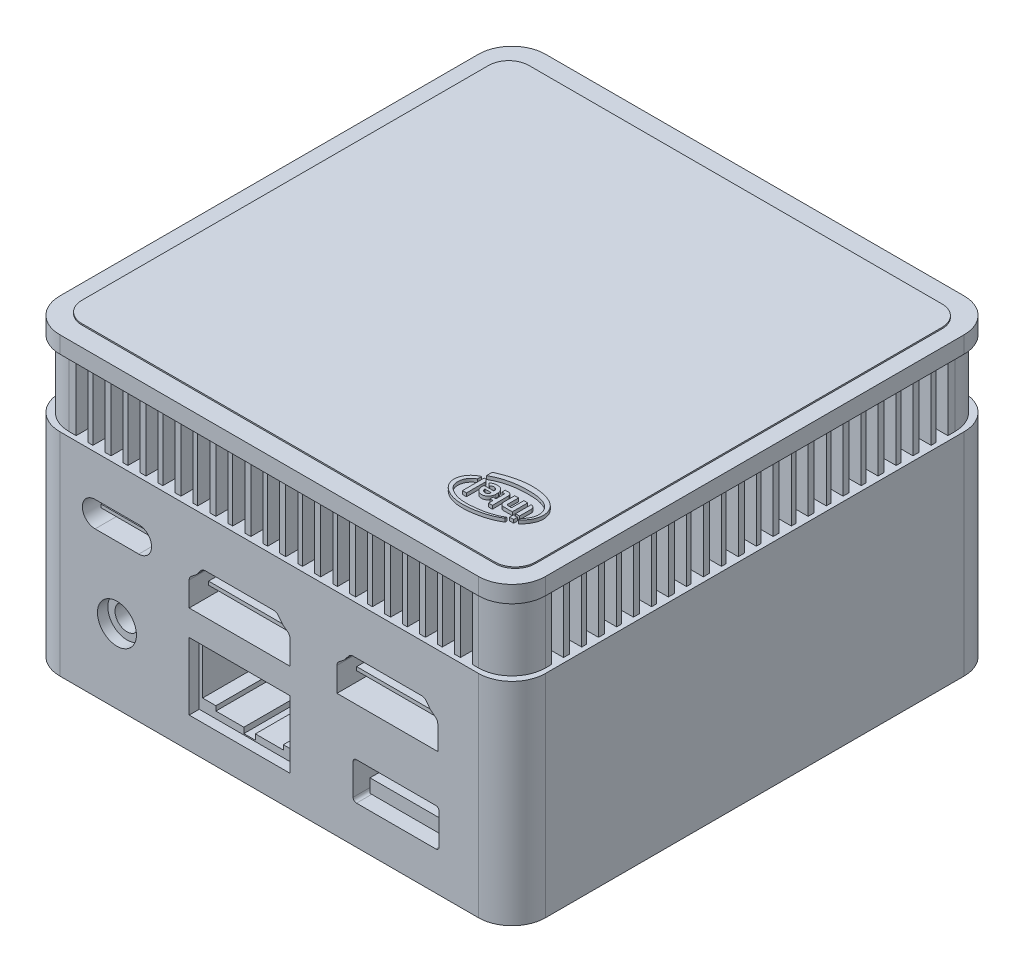
from build123d import *

# Parameters (mm, degrees)
EXTRUDE_1_DEPTH          = 31.5
EXTRUDE_2_DEPTH          = 10
SKETCH_3_W               = 1.8
SKETCH_3_H               = 4.65876044
SKETCH_3_W_2             = 4.65876044
SKETCH_3_H_2             = 1.8
CUT_EXTRUDE_1_DEPTH      = 10
EXTRUDE_3_DEPTH          = 2.5
EXTRUDE_4_DEPTH          = 0.2
SKETCH_6_R               = 5.2
SKETCH_6_R_2             = 0.75
CUT_EXTRUDE_2_DEPTH      = 0.5
CUT_EXTRUDE_3_DEPTH      = 0.5
CUT_EXTRUDE_4_DEPTH      = 10
CUT_EXTRUDE_4_DEPTH_BACK = 13.6
SKETCH_9_W               = 9.8
SKETCH_9_H               = 1.8
EXTRUDE_5_DEPTH          = 12.5
SKETCH_10_W              = 12.4
SKETCH_10_H              = 2
CUT_EXTRUDE_5_DEPTH      = 15
CUT_EXTRUDE_6_DEPTH      = 5
SKETCH_13_R              = 2.9
SKETCH_13_W              = 15
SKETCH_13_H              = 10
CUT_EXTRUDE_7_DEPTH      = 13.5
SKETCH_14_R              = 2.851807147
SKETCH_14_R_2            = 1.788206496
SKETCH_14_W              = 12.27057006
SKETCH_14_H              = 0.529318708
SKETCH_14_W_2            = 7.699181214
SKETCH_14_H_2            = 0.481198826
SKETCH_14_W_3            = 15
SKETCH_14_H_3            = 10
SKETCH_14_W_4            = 10.873667572
SKETCH_14_H_4            = 2.006450564
EXTRUDE_6_DEPTH          = 12
SKETCH_15_R              = 3.95
SKETCH_15_R_2            = 2.35
EXTRUDE_7_DEPTH          = 1.5
SKETCH_17_R              = 1
CUT_EXTRUDE_8_DEPTH      = 4
SKETCH_18_W              = 0.588452895
SKETCH_18_H              = 0.560154655
EXTRUDE_8_DEPTH          = 0.5


with BuildPart() as part:
    # 草图1 → 凸台-拉伸1 (new body)
    with BuildSketch(Plane(origin=(0, 0, 0), x_dir=(1, 0, 0), z_dir=(0, 1, 0))):
        with BuildLine():
            Line((-31.15, 36.15), (31.15, 36.15))
            ThreePointArc((31.15, 36.15), (34.685533906, 34.685533906), (36.15, 31.15))
            Line((36.15, 31.15), (36.15, -31.15))
            ThreePointArc((36.15, -31.15), (34.685533906, -34.685533906), (31.15, -36.15))
            Line((31.15, -36.15), (-31.15, -36.15))
            ThreePointArc((-31.15, -36.15), (-34.685533906, -34.685533906), (-36.15, -31.15))
            Line((-36.15, -31.15), (-36.15, 31.15))
            ThreePointArc((-36.15, 31.15), (-34.685533906, 34.685533906), (-31.15, 36.15))
        make_face()
    extrude(amount=EXTRUDE_1_DEPTH)

    # 草图2 → 凸台-拉伸2 (add)
    with BuildSketch(Plane(origin=(0, 31.5, 0), x_dir=(1, 0, 0), z_dir=(0, 1, 0))):
        with BuildLine():
            Line((-30.45, 35.45), (30.45, 35.45))
            ThreePointArc((30.45, 35.45), (33.985533906, 33.985533906), (35.45, 30.45))
            Line((35.45, 30.45), (35.45, -30.45))
            ThreePointArc((35.45, -30.45), (33.985533906, -33.985533906), (30.45, -35.45))
            Line((30.45, -35.45), (-30.45, -35.45))
            ThreePointArc((-30.45, -35.45), (-33.985533906, -33.985533906), (-35.45, -30.45))
            Line((-35.45, -30.45), (-35.45, 30.45))
            ThreePointArc((-35.45, 30.45), (-33.985533906, 33.985533906), (-30.45, 35.45))
        make_face()
    extrude(amount=EXTRUDE_2_DEPTH)

    # 草图3 → 切除-拉伸1 (cut)
    with BuildSketch(Plane(origin=(0, 41.5, 0), x_dir=(1, 0, 0), z_dir=(0, 1, 0))):
        with Locations((-28.675540816, 35.45)):
            Rectangle(SKETCH_3_W, SKETCH_3_H)
        with Locations((-25.975540816, 35.45)):
            Rectangle(SKETCH_3_W, SKETCH_3_H)
        with Locations((-20.775540816, 35.45)):
            Rectangle(SKETCH_3_W, SKETCH_3_H)
        with Locations((-23.475540816, 35.45)):
            Rectangle(SKETCH_3_W, SKETCH_3_H)
        with Locations((-15.575540816, 35.45)):
            Rectangle(SKETCH_3_W, SKETCH_3_H)
        with Locations((-18.275540816, 35.45)):
            Rectangle(SKETCH_3_W, SKETCH_3_H)
        with Locations((-10.375540816, 35.45)):
            Rectangle(SKETCH_3_W, SKETCH_3_H)
        with Locations((-13.075540816, 35.45)):
            Rectangle(SKETCH_3_W, SKETCH_3_H)
        with Locations((-5.175540816, 35.45)):
            Rectangle(SKETCH_3_W, SKETCH_3_H)
        with Locations((-7.875540816, 35.45)):
            Rectangle(SKETCH_3_W, SKETCH_3_H)
        with Locations((0.024459184, 35.45)):
            Rectangle(SKETCH_3_W, SKETCH_3_H)
        with Locations((-2.675540816, 35.45)):
            Rectangle(SKETCH_3_W, SKETCH_3_H)
        with Locations((5.224459184, 35.45)):
            Rectangle(SKETCH_3_W, SKETCH_3_H)
        with Locations((2.524459184, 35.45)):
            Rectangle(SKETCH_3_W, SKETCH_3_H)
        with Locations((10.424459184, 35.45)):
            Rectangle(SKETCH_3_W, SKETCH_3_H)
        with Locations((7.724459184, 35.45)):
            Rectangle(SKETCH_3_W, SKETCH_3_H)
        with Locations((15.624459184, 35.45)):
            Rectangle(SKETCH_3_W, SKETCH_3_H)
        with Locations((12.924459184, 35.45)):
            Rectangle(SKETCH_3_W, SKETCH_3_H)
        with Locations((20.824459184, 35.45)):
            Rectangle(SKETCH_3_W, SKETCH_3_H)
        with Locations((18.124459184, 35.45)):
            Rectangle(SKETCH_3_W, SKETCH_3_H)
        with Locations((26.024459184, 35.45)):
            Rectangle(SKETCH_3_W, SKETCH_3_H)
        with Locations((23.324459184, 35.45)):
            Rectangle(SKETCH_3_W, SKETCH_3_H)
        with Locations((28.524459184, 35.45)):
            Rectangle(SKETCH_3_W, SKETCH_3_H)
        with Locations((-35.45, -28.524459184)):
            Rectangle(SKETCH_3_W_2, SKETCH_3_H_2)
        with Locations((-35.45, -23.324459184)):
            Rectangle(SKETCH_3_W_2, SKETCH_3_H_2)
        with Locations((-35.45, -26.024459184)):
            Rectangle(SKETCH_3_W_2, SKETCH_3_H_2)
        with Locations((-35.45, -18.124459184)):
            Rectangle(SKETCH_3_W_2, SKETCH_3_H_2)
        with Locations((-35.45, -20.824459184)):
            Rectangle(SKETCH_3_W_2, SKETCH_3_H_2)
        with Locations((-35.45, -12.924459184)):
            Rectangle(SKETCH_3_W_2, SKETCH_3_H_2)
        with Locations((-35.45, -15.624459184)):
            Rectangle(SKETCH_3_W_2, SKETCH_3_H_2)
        with Locations((-35.45, -7.724459184)):
            Rectangle(SKETCH_3_W_2, SKETCH_3_H_2)
        with Locations((-35.45, -10.424459184)):
            Rectangle(SKETCH_3_W_2, SKETCH_3_H_2)
        with Locations((-35.45, -2.524459184)):
            Rectangle(SKETCH_3_W_2, SKETCH_3_H_2)
        with Locations((-35.45, -5.224459184)):
            Rectangle(SKETCH_3_W_2, SKETCH_3_H_2)
        with Locations((-35.45, 2.675540816)):
            Rectangle(SKETCH_3_W_2, SKETCH_3_H_2)
        with Locations((-35.45, -0.024459184)):
            Rectangle(SKETCH_3_W_2, SKETCH_3_H_2)
        with Locations((-35.45, 7.875540816)):
            Rectangle(SKETCH_3_W_2, SKETCH_3_H_2)
        with Locations((-35.45, 5.175540816)):
            Rectangle(SKETCH_3_W_2, SKETCH_3_H_2)
        with Locations((-35.45, 13.075540816)):
            Rectangle(SKETCH_3_W_2, SKETCH_3_H_2)
        with Locations((-35.45, 10.375540816)):
            Rectangle(SKETCH_3_W_2, SKETCH_3_H_2)
        with Locations((-35.45, 18.275540816)):
            Rectangle(SKETCH_3_W_2, SKETCH_3_H_2)
        with Locations((-35.45, 15.575540816)):
            Rectangle(SKETCH_3_W_2, SKETCH_3_H_2)
        with Locations((-35.45, 23.475540816)):
            Rectangle(SKETCH_3_W_2, SKETCH_3_H_2)
        with Locations((-35.45, 20.775540816)):
            Rectangle(SKETCH_3_W_2, SKETCH_3_H_2)
        with Locations((-35.45, 25.975540816)):
            Rectangle(SKETCH_3_W_2, SKETCH_3_H_2)
        with Locations((-35.45, 28.675540816)):
            Rectangle(SKETCH_3_W_2, SKETCH_3_H_2)
        with Locations((28.675540816, -35.45)):
            Rectangle(SKETCH_3_W, SKETCH_3_H)
        with Locations((25.975540816, -35.45)):
            Rectangle(SKETCH_3_W, SKETCH_3_H)
        with Locations((20.775540816, -35.45)):
            Rectangle(SKETCH_3_W, SKETCH_3_H)
        with Locations((23.475540816, -35.45)):
            Rectangle(SKETCH_3_W, SKETCH_3_H)
        with Locations((15.575540816, -35.45)):
            Rectangle(SKETCH_3_W, SKETCH_3_H)
        with Locations((18.275540816, -35.45)):
            Rectangle(SKETCH_3_W, SKETCH_3_H)
        with Locations((10.375540816, -35.45)):
            Rectangle(SKETCH_3_W, SKETCH_3_H)
        with Locations((13.075540816, -35.45)):
            Rectangle(SKETCH_3_W, SKETCH_3_H)
        with Locations((5.175540816, -35.45)):
            Rectangle(SKETCH_3_W, SKETCH_3_H)
        with Locations((7.875540816, -35.45)):
            Rectangle(SKETCH_3_W, SKETCH_3_H)
        with Locations((-0.024459184, -35.45)):
            Rectangle(SKETCH_3_W, SKETCH_3_H)
        with Locations((2.675540816, -35.45)):
            Rectangle(SKETCH_3_W, SKETCH_3_H)
        with Locations((-5.224459184, -35.45)):
            Rectangle(SKETCH_3_W, SKETCH_3_H)
        with Locations((-2.524459184, -35.45)):
            Rectangle(SKETCH_3_W, SKETCH_3_H)
        with Locations((-10.424459184, -35.45)):
            Rectangle(SKETCH_3_W, SKETCH_3_H)
        with Locations((-7.724459184, -35.45)):
            Rectangle(SKETCH_3_W, SKETCH_3_H)
        with Locations((-15.624459184, -35.45)):
            Rectangle(SKETCH_3_W, SKETCH_3_H)
        with Locations((-12.924459184, -35.45)):
            Rectangle(SKETCH_3_W, SKETCH_3_H)
        with Locations((-20.824459184, -35.45)):
            Rectangle(SKETCH_3_W, SKETCH_3_H)
        with Locations((-18.124459184, -35.45)):
            Rectangle(SKETCH_3_W, SKETCH_3_H)
        with Locations((-26.024459184, -35.45)):
            Rectangle(SKETCH_3_W, SKETCH_3_H)
        with Locations((-23.324459184, -35.45)):
            Rectangle(SKETCH_3_W, SKETCH_3_H)
        with Locations((-28.524459184, -35.45)):
            Rectangle(SKETCH_3_W, SKETCH_3_H)
        with Locations((35.45, 28.524459184)):
            Rectangle(SKETCH_3_W_2, SKETCH_3_H_2)
        with Locations((35.45, 23.324459184)):
            Rectangle(SKETCH_3_W_2, SKETCH_3_H_2)
        with Locations((35.45, 26.024459184)):
            Rectangle(SKETCH_3_W_2, SKETCH_3_H_2)
        with Locations((35.45, 18.124459184)):
            Rectangle(SKETCH_3_W_2, SKETCH_3_H_2)
        with Locations((35.45, 20.824459184)):
            Rectangle(SKETCH_3_W_2, SKETCH_3_H_2)
        with Locations((35.45, 12.924459184)):
            Rectangle(SKETCH_3_W_2, SKETCH_3_H_2)
        with Locations((35.45, 15.624459184)):
            Rectangle(SKETCH_3_W_2, SKETCH_3_H_2)
        with Locations((35.45, 7.724459184)):
            Rectangle(SKETCH_3_W_2, SKETCH_3_H_2)
        with Locations((35.45, 10.424459184)):
            Rectangle(SKETCH_3_W_2, SKETCH_3_H_2)
        with Locations((35.45, 2.524459184)):
            Rectangle(SKETCH_3_W_2, SKETCH_3_H_2)
        with Locations((35.45, 5.224459184)):
            Rectangle(SKETCH_3_W_2, SKETCH_3_H_2)
        with Locations((35.45, -2.675540816)):
            Rectangle(SKETCH_3_W_2, SKETCH_3_H_2)
        with Locations((35.45, 0.024459184)):
            Rectangle(SKETCH_3_W_2, SKETCH_3_H_2)
        with Locations((35.45, -7.875540816)):
            Rectangle(SKETCH_3_W_2, SKETCH_3_H_2)
        with Locations((35.45, -5.175540816)):
            Rectangle(SKETCH_3_W_2, SKETCH_3_H_2)
        with Locations((35.45, -13.075540816)):
            Rectangle(SKETCH_3_W_2, SKETCH_3_H_2)
        with Locations((35.45, -10.375540816)):
            Rectangle(SKETCH_3_W_2, SKETCH_3_H_2)
        with Locations((35.45, -18.275540816)):
            Rectangle(SKETCH_3_W_2, SKETCH_3_H_2)
        with Locations((35.45, -15.575540816)):
            Rectangle(SKETCH_3_W_2, SKETCH_3_H_2)
        with Locations((35.45, -23.475540816)):
            Rectangle(SKETCH_3_W_2, SKETCH_3_H_2)
        with Locations((35.45, -20.775540816)):
            Rectangle(SKETCH_3_W_2, SKETCH_3_H_2)
        with Locations((35.45, -25.975540816)):
            Rectangle(SKETCH_3_W_2, SKETCH_3_H_2)
        with Locations((35.45, -28.675540816)):
            Rectangle(SKETCH_3_W_2, SKETCH_3_H_2)
    extrude(amount=-CUT_EXTRUDE_1_DEPTH, mode=Mode.SUBTRACT)

    # 草图4 → 凸台-拉伸3 (add)
    with BuildSketch(Plane(origin=(0, 41.5, 0), x_dir=(1, 0, 0), z_dir=(0, 1, 0))):
        with BuildLine():
            Line((-31.15, -36.15), (31.15, -36.15))
            ThreePointArc((31.15, -36.15), (34.685533906, -34.685533906), (36.15, -31.15))
            Line((36.15, -31.15), (36.15, 31.15))
            ThreePointArc((36.15, 31.15), (34.685533906, 34.685533906), (31.15, 36.15))
            Line((31.15, 36.15), (-31.15, 36.15))
            ThreePointArc((-31.15, 36.15), (-34.685533906, 34.685533906), (-36.15, 31.15))
            Line((-36.15, 31.15), (-36.15, -31.15))
            ThreePointArc((-36.15, -31.15), (-34.685533906, -34.685533906), (-31.15, -36.15))
        make_face()
    extrude(amount=EXTRUDE_3_DEPTH)

    # 草图5 → 凸台-拉伸4 (add)
    with BuildSketch(Plane(origin=(0, 44, 0), x_dir=(1, 0, 0), z_dir=(0, 1, 0))):
        with BuildLine():
            Line((-30.75, 33.26831589), (30.75, 33.26831589))
            ThreePointArc((30.75, 33.26831589), (32.871320344, 32.389636233), (33.75, 30.26831589))
            Line((33.75, 30.26831589), (33.75, -30.26831589))
            ThreePointArc((33.75, -30.26831589), (32.871320344, -32.389636233), (30.75, -33.26831589))
            Line((30.75, -33.26831589), (-30.75, -33.26831589))
            ThreePointArc((-30.75, -33.26831589), (-32.871320344, -32.389636233), (-33.75, -30.26831589))
            Line((-33.75, -30.26831589), (-33.75, 30.26831589))
            ThreePointArc((-33.75, 30.26831589), (-32.871320344, 32.389636233), (-30.75, 33.26831589))
        make_face()
    extrude(amount=EXTRUDE_4_DEPTH)

    # 草图6 → 切除-拉伸2 (cut)
    with BuildSketch(Plane(origin=(0, 0, -36.15), x_dir=(-1, 0, 0), z_dir=(0, 0, -1))):
        with Locations((-20.65, 21)):
            Circle(SKETCH_6_R)
        with Locations((-20.65, 21)):
            Circle(SKETCH_6_R_2, mode=Mode.SUBTRACT)
    extrude(amount=-CUT_EXTRUDE_2_DEPTH, mode=Mode.SUBTRACT)

    # 草图7 → 切除-拉伸3 (cut)
    with BuildSketch(Plane(origin=(0, 0, -36.15), x_dir=(-1, 0, 0), z_dir=(0, 0, -1))):
        with BuildLine():
            Line((-7.35, 23), (26.15, 23))
            ThreePointArc((26.15, 23), (27.564213562, 22.414213562), (28.15, 21))
            Line((28.15, 21), (28.15, 15))
            ThreePointArc((28.15, 15), (27.564213562, 13.585786438), (26.15, 13))
            Line((26.15, 13), (-7.35, 13))
            ThreePointArc((-7.35, 13), (-8.764213562, 13.585786438), (-9.35, 15))
            Line((-9.35, 15), (-9.35, 21))
            ThreePointArc((-9.35, 21), (-8.764213562, 22.414213562), (-7.35, 23))
        make_face()
    extrude(amount=-CUT_EXTRUDE_3_DEPTH, mode=Mode.SUBTRACT)

    # 草图8 → 切除-拉伸4 (cut, two sides)
    with BuildSketch(Plane(origin=(0, 0, -35.65), x_dir=(-1, 0, 0), z_dir=(0, 0, -1))) as cut_extrude_4_sk:
        with BuildLine():
            Line((-6.55, 20.8), (4.65, 20.8))
            ThreePointArc((4.65, 20.8), (5.215685425, 20.565685425), (5.45, 20))
            Line((5.45, 20), (5.45, 16))
            ThreePointArc((5.45, 16), (5.215685425, 15.434314575), (4.65, 15.2))
            Line((4.65, 15.2), (-6.55, 15.2))
            ThreePointArc((-6.55, 15.2), (-7.115685425, 15.434314575), (-7.35, 16))
            Line((-7.35, 16), (-7.35, 20))
            ThreePointArc((-7.35, 20), (-7.115685425, 20.565685425), (-6.55, 20.8))
        make_face()
        with BuildLine():
            Line((14.25, 20.8), (25.45, 20.8))
            ThreePointArc((25.45, 20.8), (26.015685425, 20.565685425), (26.25, 20))
            Line((26.25, 20), (26.25, 16))
            ThreePointArc((26.25, 16), (26.015685425, 15.434314575), (25.45, 15.2))
            Line((25.45, 15.2), (14.25, 15.2))
            ThreePointArc((14.25, 15.2), (13.684314575, 15.434314575), (13.45, 16))
            Line((13.45, 16), (13.45, 20))
            ThreePointArc((13.45, 20), (13.684314575, 20.565685425), (14.25, 20.8))
        make_face()
    extrude(amount=CUT_EXTRUDE_4_DEPTH, mode=Mode.SUBTRACT)
    extrude(cut_extrude_4_sk.sketch, amount=-CUT_EXTRUDE_4_DEPTH_BACK, mode=Mode.SUBTRACT)

    # 草图9 → 凸台-拉伸5 (add)
    with BuildSketch(Plane(origin=(0, 0, -22.05), x_dir=(-1, 0, 0), z_dir=(0, 0, -1))):
        with Locations((-0.95, 18.9)):
            Rectangle(SKETCH_9_W, SKETCH_9_H)
        with Locations((19.85, 18.9)):
            Rectangle(SKETCH_9_W, SKETCH_9_H)
    extrude(amount=EXTRUDE_5_DEPTH)

    # 草图10 → 切除-拉伸5 (cut)
    with BuildSketch(Plane.ZY.offset(36.15)):
        with Locations((-8.95, 12)):
            Rectangle(SKETCH_10_W, SKETCH_10_H)
    extrude(amount=-CUT_EXTRUDE_5_DEPTH, mode=Mode.SUBTRACT)

    # 草图12 → 切除-拉伸6 (cut)
    with BuildSketch(Plane.ZY.offset(36.15)):
        with BuildLine():
            Line((11.35, 15.7), (17.65, 15.7))
            ThreePointArc((17.65, 15.7), (18.003553391, 15.553553391), (18.15, 15.2))
            Line((18.15, 15.2), (18.15, 11.7))
            ThreePointArc((18.15, 11.7), (18.003553391, 11.346446609), (17.65, 11.2))
            Line((17.65, 11.2), (11.35, 11.2))
            ThreePointArc((11.35, 11.2), (10.996446609, 11.346446609), (10.85, 11.7))
            Line((10.85, 11.7), (10.85, 15.2))
            ThreePointArc((10.85, 15.2), (10.996446609, 15.553553391), (11.35, 15.7))
        make_face()
    extrude(amount=-CUT_EXTRUDE_6_DEPTH, mode=Mode.SUBTRACT)

    # 草图13 → 切除-拉伸7 (cut)
    with BuildSketch(Plane.XY.offset(36.15)):
        with Locations((-22.65, 11)):
            Circle(SKETCH_13_R)
        with BuildLine():
            Line((-25.9, 25.4), (-19.4, 25.4))
            ThreePointArc((-19.4, 25.4), (-17.5, 23.5), (-19.4, 21.6))
            Line((-19.4, 21.6), (-25.9, 21.6))
            ThreePointArc((-25.9, 21.6), (-27.8, 23.5), (-25.9, 25.4))
        make_face()
        with BuildLine():
            Line((-11.9, 22.006931899), (-11.9, 18.4))
            Line((-11.9, 18.4), (3.1, 18.4))
            Line((3.1, 18.4), (3.1, 22.006931899))
            ThreePointArc((3.1, 22.006931899), (3.018013039, 22.359716926), (2.788856812, 22.640192523))
            Line((2.788856812, 22.640192523), (2.095640773, 23.175332984))
            ThreePointArc((2.095640773, 23.175332984), (2.018812159, 23.242908183), (1.95123696, 23.319736797))
            Line((1.95123696, 23.319736797), (1.357501074, 24.088856812))
            ThreePointArc((1.357501074, 24.088856812), (1.077025477, 24.318013039), (0.72424045, 24.4))
            Line((0.72424045, 24.4), (-9.52424045, 24.4))
            ThreePointArc((-9.52424045, 24.4), (-9.877025477, 24.318013039), (-10.157501074, 24.088856812))
            Line((-10.157501074, 24.088856812), (-10.75123696, 23.319736797))
            ThreePointArc((-10.75123696, 23.319736797), (-10.818812159, 23.242908183), (-10.895640773, 23.175332984))
            Line((-10.895640773, 23.175332984), (-11.588856812, 22.640192523))
            ThreePointArc((-11.588856812, 22.640192523), (-11.818013039, 22.359716926), (-11.9, 22.006931899))
        make_face()
        with Locations((-4.4, 9.6)):
            Rectangle(SKETCH_13_W, SKETCH_13_H)
        with BuildLine():
            Line((10.1, 22.006931899), (10.1, 18.4))
            Line((10.1, 18.4), (25.1, 18.4))
            Line((25.1, 18.4), (25.1, 22.006931899))
            ThreePointArc((25.1, 22.006931899), (25.018013039, 22.359716926), (24.788856812, 22.640192523))
            Line((24.788856812, 22.640192523), (24.095640773, 23.175332984))
            ThreePointArc((24.095640773, 23.175332984), (24.018812159, 23.242908183), (23.95123696, 23.319736797))
            Line((23.95123696, 23.319736797), (23.357501074, 24.088856812))
            ThreePointArc((23.357501074, 24.088856812), (23.077025477, 24.318013039), (22.72424045, 24.4))
            Line((22.72424045, 24.4), (12.47575955, 24.4))
            ThreePointArc((12.47575955, 24.4), (12.122974523, 24.318013039), (11.842498926, 24.088856812))
            Line((11.842498926, 24.088856812), (11.24876304, 23.319736797))
            ThreePointArc((11.24876304, 23.319736797), (11.181187841, 23.242908183), (11.104359227, 23.175332984))
            Line((11.104359227, 23.175332984), (10.411143188, 22.640192523))
            ThreePointArc((10.411143188, 22.640192523), (10.181986961, 22.359716926), (10.1, 22.006931899))
        make_face()
        with BuildLine():
            Line((13, 11.3), (24.8, 11.3))
            ThreePointArc((24.8, 11.3), (25.153553391, 11.153553391), (25.3, 10.8))
            Line((25.3, 10.8), (25.3, 6.2))
            ThreePointArc((25.3, 6.2), (25.153553391, 5.846446609), (24.8, 5.7))
            Line((24.8, 5.7), (13, 5.7))
            ThreePointArc((13, 5.7), (12.646446609, 5.846446609), (12.5, 6.2))
            Line((12.5, 6.2), (12.5, 10.8))
            ThreePointArc((12.5, 10.8), (12.646446609, 11.153553391), (13, 11.3))
        make_face()
    extrude(amount=-CUT_EXTRUDE_7_DEPTH, mode=Mode.SUBTRACT)

    # 草图14 → 凸台-拉伸6 (add)
    with BuildSketch(Plane.XY.offset(22.65)):
        with Locations((-22.65, 11)):
            Circle(SKETCH_14_R)
        with Locations((-22.65, 11)):
            Circle(SKETCH_14_R_2, mode=Mode.SUBTRACT)
        with Locations((17.672745661, 21.54662135)):
            Rectangle(SKETCH_14_W, SKETCH_14_H)
        with Locations((-22.68852464, 23.495476595)):
            Rectangle(SKETCH_14_W_2, SKETCH_14_H_2)
        with Locations((-4.378909316, 21.54662135)):
            Rectangle(SKETCH_14_W, SKETCH_14_H)
        with Locations((-4.4, 9.6)):
            Rectangle(SKETCH_14_W_3, SKETCH_14_H_3)
        Polygon((-11.4, 14.095061531), (-11.4, 6.294314474), (-9.42049085, 6.294314474), (-9.42049085, 5.605542147), (-5.258720162, 5.605542147), (-5.258720162, 4.778804827), (-3.541279838, 4.778804827), (-3.541279838, 5.605542147), (0.62049085, 5.605542147), (0.62049085, 6.294314474), (2.6, 6.294314474), (2.6, 14.095061531), align=None, mode=Mode.SUBTRACT)
        with Locations((18.952613797, 7.467625954)):
            Rectangle(SKETCH_14_W_4, SKETCH_14_H_4)
    extrude(amount=EXTRUDE_6_DEPTH)

    # 草图15 → 凸台-拉伸7 (add)
    with BuildSketch(Plane.XZ):
        with Locations((29.25, 29.25)):
            Circle(SKETCH_15_R)
        with Locations((29.25, 29.25)):
            Circle(SKETCH_15_R_2, mode=Mode.SUBTRACT)
        with Locations((-29.25, 29.25)):
            Circle(SKETCH_15_R)
        with Locations((-29.25, 29.25)):
            Circle(SKETCH_15_R_2, mode=Mode.SUBTRACT)
        with Locations((-29.25, -29.25)):
            Circle(SKETCH_15_R)
        with Locations((-29.25, -29.25)):
            Circle(SKETCH_15_R_2, mode=Mode.SUBTRACT)
        with Locations((29.25, -29.25)):
            Circle(SKETCH_15_R)
        with Locations((29.25, -29.25)):
            Circle(SKETCH_15_R_2, mode=Mode.SUBTRACT)
    extrude(amount=EXTRUDE_7_DEPTH)

    # 草图17 → 切除-拉伸8 (cut)
    with BuildSketch(Plane.XZ):
        with Locations((27.25, 0)):
            Circle(SKETCH_17_R)
        with Locations((-27.25, 0)):
            Circle(SKETCH_17_R)
    extrude(amount=-CUT_EXTRUDE_8_DEPTH, mode=Mode.SUBTRACT)

    # 草图18 → 凸台-拉伸8 (add)
    with BuildSketch(Plane(origin=(0, 44.2, 0), x_dir=(1, 0, 0), z_dir=(0, 1, 0))):
        with BuildLine():
            Line((27.129073137, -26.007984189), (27.129073137, -24.22823144))
            add(Edge.make_bspline(
                [(27.129073137, -24.22823144), (27.066600773, -23.814474055), (26.797568667, -23.691408765), (26.53341077, -23.704149535)],
                knots=[0, 0, 0, 0, 1, 1, 1, 1], degree=3))
            Line((26.53341077, -23.704149535), (26.53341077, -26.007984189))
            Line((26.53341077, -26.007984189), (27.129073137, -26.007984189))
        make_face()
        with Locations((26.83484669, -26.610952158)):
            Rectangle(SKETCH_18_W, SKETCH_18_H)
        with BuildLine():
            Line((26.043235848, -26.004453525), (26.043235848, -23.700618871))
            Line((26.043235848, -23.700618871), (25.465757492, -23.700618871))
            Line((25.465757492, -23.700618871), (25.465757492, -25.537976363))
            Line((25.465757492, -25.537976363), (24.903563318, -25.537976363))
            ThreePointArc((24.903563318, -25.537976363), (24.778784674, -25.486291357), (24.727099667, -25.361512713))
            Line((24.727099667, -25.361512713), (24.727099667, -23.742373005))
            Line((24.727099667, -23.742373005), (24.151434589, -23.742373005))
            Line((24.151434589, -23.742373005), (24.151434589, -25.360112493))
            ThreePointArc((24.151434589, -25.360112493), (24.285927469, -25.793267506), (24.687315144, -26.004453525))
            Line((24.687315144, -26.004453525), (26.043235848, -26.004453525))
        make_face()
        with BuildLine():
            Line((23.742604959, -26.654378496), (23.709253493, -24.235479724))
            ThreePointArc((23.709253493, -24.235479724), (23.560408802, -23.886390814), (23.209301013, -23.742373005))
            Line((23.209301013, -23.742373005), (22.729565957, -23.742373005))
            Line((22.729565957, -23.742373005), (22.729565957, -24.22823144))
            Line((22.729565957, -24.22823144), (23.057618269, -24.22823144))
            ThreePointArc((23.057618269, -24.22823144), (23.128328947, -24.257520762), (23.157618269, -24.32823144))
            Line((23.157618269, -24.32823144), (23.157618269, -25.537976363))
            Line((23.157618269, -25.537976363), (22.729565957, -25.537976363))
            Line((22.729565957, -25.537976363), (22.729565957, -26.004453525))
            Line((22.729565957, -26.004453525), (23.157618269, -26.004453525))
            Line((23.157618269, -26.004453525), (23.157618269, -26.654378496))
            Line((23.157618269, -26.654378496), (23.742604959, -26.654378496))
        make_face()
        with BuildLine():
            Line((21.982172995, -24.695934008), (20.532790175, -24.695934008))
            Line((20.532790175, -24.695934008), (20.532790175, -25.105952358))
            add(Edge.make_bspline(
                [(20.532790175, -25.105952358), (20.562308872, -25.407205172), (20.810326182, -25.906895532), (21.51736502, -26.130579176), (22.042005392, -25.964783057), (22.415067576, -25.569579534), (22.566331481, -25.246784759), (22.5630427, -25.029861308)],
                knots=[0, 0, 0, 0, 0.296942068, 0.479882096, 0.672020869, 0.792857169, 1, 1, 1, 1], degree=3))
            Line((22.5630427, -25.029861308), (22.5630427, -24.562833844))
            add(Edge.make_bspline(
                [(22.5630427, -24.562833844), (22.492896179, -24.292522076), (22.278247788, -23.789783596), (21.67795316, -23.688902114), (21.15389865, -23.676524076), (20.800560885, -23.827592912), (20.613340229, -24.035322291)],
                knots=[0, 0, 0, 0, 0.371759734, 0.531549348, 0.708197123, 1, 1, 1, 1], degree=3))
            Line((20.613340229, -24.035322291), (20.985132104, -24.370407868))
            add(Edge.make_bspline(
                [(20.985132104, -24.370407868), (21.137847159, -24.190500715), (21.684647067, -23.997247333), (22.031833994, -24.467958053), (21.982172995, -24.695934008)],
                knots=[0, 0, 0, 0, 0.525584724, 1, 1, 1, 1], degree=3))
        make_face()
        with BuildLine():
            Line((22.014286761, -25.105952358), (21.09669675, -25.105952358))
            add(Edge.make_bspline(
                [(21.09669675, -25.105952358), (21.042246761, -25.327326273), (21.308676053, -25.565556433), (21.818407162, -25.581942327), (22.049121848, -25.296970874), (22.014286761, -25.105952358)],
                knots=[0, 0, 0, 0, 0.395149551, 0.622029631, 1, 1, 1, 1], degree=3))
        make_face(mode=Mode.SUBTRACT)
        with BuildLine():
            Line((20.197172777, -26.977052583), (19.605517831, -26.977052583))
            Line((19.605517831, -26.977052583), (19.605517831, -23.742373005))
            ThreePointArc((19.605517831, -23.742373005), (19.996716335, -23.850083291), (20.197172777, -24.202865079))
            Line((20.197172777, -24.202865079), (20.197172777, -26.977052583))
        make_face()
        with BuildLine():
            Line((26.347312265, -27.372829703), (26.347312265, -27.12301762))
            add(Edge.make_bspline(
                [(26.347312265, -27.12301762), (25.782489844, -27.45327884), (24.643046172, -27.940634291), (22.755599342, -28.267237301), (20.848389469, -28.405146381), (19.17735481, -27.931206668), (17.642577611, -26.513455574), (18.291415458, -24.723070489), (19.215458345, -24.370407868)],
                knots=[0, 0, 0, 0, 0.168706271, 0.31599894, 0.492217069, 0.65777956, 0.750336935, 1, 1, 1, 1], degree=3))
            Line((19.215458345, -24.370407868), (19.215458345, -23.742373005))
            add(Edge.make_bspline(
                [(26.347312265, -27.372829703), (25.909535926, -27.634537859), (25.10402656, -28.056371289), (23.654653073, -28.477185932), (21.655302616, -28.834565117), (19.332414137, -28.658360388), (17.685621439, -27.339090899), (17.251930956, -25.3740535), (18.280129994, -24.084747001), (19.215458345, -23.742373005)],
                knots=[0, 0, 0, 0, 0.114361215, 0.202297192, 0.336551315, 0.570143048, 0.699874968, 0.774598127, 1, 1, 1, 1], degree=3))
        make_face()
        with BuildLine():
            Line((27.5519249, -26.610952157), (27.5519249, -26.207412811))
            add(Edge.make_bspline(
                [(27.5519249, -26.207412811), (28.048294743, -25.735477188), (28.695627846, -24.517144932), (27.949220776, -22.828614357), (26.384915939, -22.130030089), (23.488395689, -21.921136283), (21.013694529, -22.347475284), (19.45734355, -23.255435874)],
                knots=[0, 0, 0, 0, 0.169965794, 0.29675149, 0.399644527, 0.571507802, 1, 1, 1, 1], degree=3))
            Line((19.45734355, -23.255435874), (19.45734355, -22.40015736))
            add(Edge.make_bspline(
                [(27.5519249, -26.610952157), (28.199189315, -26.041576974), (29.080295368, -24.716565249), (28.597610519, -22.776247568), (27.308161488, -21.704667497), (25.525920984, -21.232697416), (22.737727448, -21.153329025), (20.699648049, -21.846616709), (19.45734355, -22.40015736)],
                knots=[0, 0, 0, 0, 0.192044384, 0.310009287, 0.397860736, 0.544360694, 0.701771966, 1, 1, 1, 1], degree=3))
        make_face()
    extrude(amount=EXTRUDE_8_DEPTH)


solid = part.part
